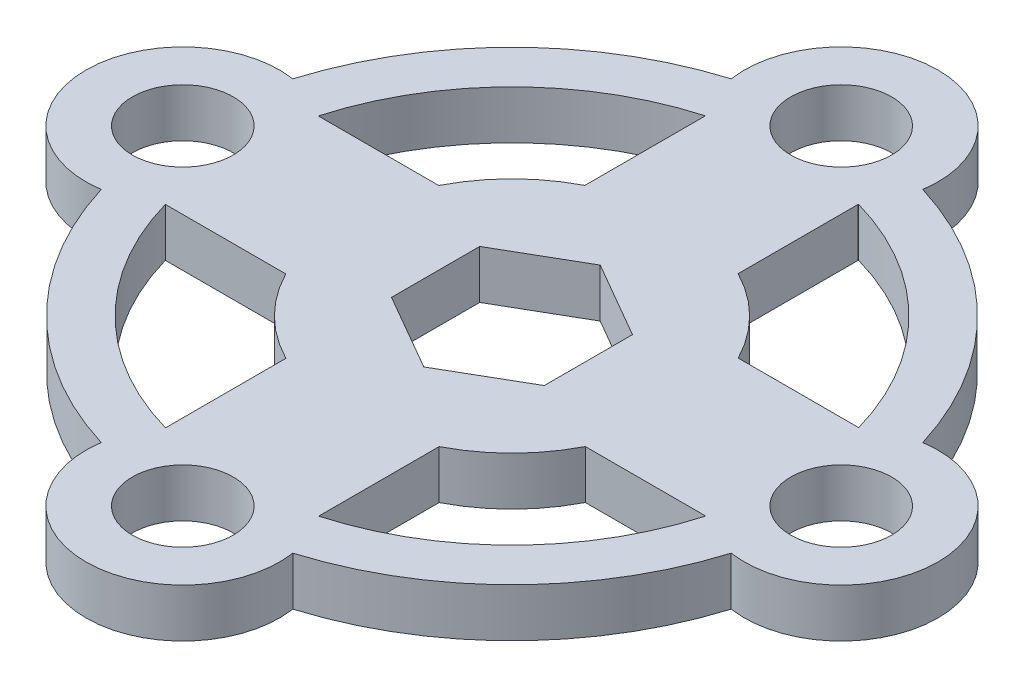
from build123d import *

# Parameters (mm, degrees)
SKETCH1_R           = 6.339
SKETCH1_R_2         = 3.302
SKETCH1_R_3         = 11
BOSS_EXTRUDE1_DEPTH = 3.175


with BuildPart() as part:
    # Sketch1 → Boss-Extrude1 (new body)
    with BuildSketch(Plane(origin=(0, 0, 0), x_dir=(1, 0, 0), z_dir=(0, 1, 0))):
        with BuildLine():
            ThreePointArc((-17.674506033, 5.017864634), (-12.991672891, 12.991672891), (-5.017864634, 17.674506033))
            ThreePointArc((-5.017864634, 17.674506033), (-5.832389069, 19.064824865), (-6.270051206, 20.615595113))
            ThreePointArc((-6.270051206, 20.615595113), (-15.236736921, 15.236736921), (-20.615595113, 6.270051206))
            ThreePointArc((-20.615595113, 6.270051206), (-19.064824865, 5.832389069), (-17.674506033, 5.017864634))
        make_face()
        with Locations((-21.548, 0)):
            Circle(SKETCH1_R)
        with Locations((-21.548, 0)):
            Circle(SKETCH1_R_2, mode=Mode.SUBTRACT)
        with BuildLine():
            ThreePointArc((-17.674506033, -5.017864634), (-19.064824865, -5.832389069), (-20.615595113, -6.270051206))
            ThreePointArc((-20.615595113, -6.270051206), (-15.236736921, -15.236736921), (-6.270051206, -20.615595113))
            ThreePointArc((-6.270051206, -20.615595113), (-5.832389069, -19.064824865), (-5.017864634, -17.674506033))
            ThreePointArc((-5.017864634, -17.674506033), (-12.991672891, -12.991672891), (-17.674506033, -5.017864634))
        make_face()
        with Locations((0, -21.548)):
            Circle(SKETCH1_R)
        with Locations((0, -21.548)):
            Circle(SKETCH1_R_2, mode=Mode.SUBTRACT)
        with BuildLine():
            ThreePointArc((-9.788821916, -5.017864634), (-10.999995425, -0.010032833), (-9.797958971, 5))
            Line((-9.797958971, 5), (-17.651473213, 5))
            ThreePointArc((-17.651473213, 5), (-15.852255786, 2.782340534), (-15.209, 0))
            ThreePointArc((-15.209, 0), (-15.85866791, -2.795428656), (-17.674506033, -5.017864634))
            Line((-17.674506033, -5.017864634), (-9.788821916, -5.017864634))
        make_face()
        with BuildLine():
            ThreePointArc((5.017864634, -9.788821916), (0.010032833, -10.999995425), (-5, -9.797958971))
            Line((-5, -9.797958971), (-5, -17.651473213))
            ThreePointArc((-5, -17.651473213), (0.014574429, -15.209016755), (5.017864634, -17.674506033))
            Line((5.017864634, -17.674506033), (5.017864634, -9.788821916))
        make_face()
        Circle(SKETCH1_R_3)
        Polygon((5, 2.886751346), (0, 5.773502692), (-5, 2.886751346), (-5, -2.886751346), (0, -5.773502692), (5, -2.886751346), align=None, mode=Mode.SUBTRACT)
        with BuildLine():
            ThreePointArc((5, 17.651473213), (-0.014574429, 15.209016755), (-5.017864634, 17.674506033))
            Line((-5.017864634, 17.674506033), (-5.017864634, 9.788821916))
            ThreePointArc((-5.017864634, 9.788821916), (-0.010032833, 10.999995425), (5, 9.797958971))
            Line((5, 9.797958971), (5, 17.651473213))
        make_face()
        with Locations((0, 21.548)):
            Circle(SKETCH1_R)
        with Locations((0, 21.548)):
            Circle(SKETCH1_R_2, mode=Mode.SUBTRACT)
        with BuildLine():
            ThreePointArc((6.270051206, 20.615595113), (5.832389069, 19.064824865), (5.017864634, 17.674506033))
            ThreePointArc((5.017864634, 17.674506033), (12.991672891, 12.991672891), (17.674506033, 5.017864634))
            ThreePointArc((17.674506033, 5.017864634), (19.064824865, 5.832389069), (20.615595113, 6.270051206))
            ThreePointArc((20.615595113, 6.270051206), (15.236736921, 15.236736921), (6.270051206, 20.615595113))
        make_face()
        with BuildLine():
            Line((17.674506033, 5.017864634), (9.788821916, 5.017864634))
            ThreePointArc((9.788821916, 5.017864634), (10.692919178, 2.580984204), (11, 0))
            ThreePointArc((11, 0), (10.695268783, -2.571230378), (9.797958971, -5))
            Line((9.797958971, -5), (17.651473213, -5))
            ThreePointArc((17.651473213, -5), (15.209016755, 0.014574429), (17.674506033, 5.017864634))
        make_face()
        with Locations((21.548, 0)):
            Circle(SKETCH1_R)
        with Locations((21.548, 0)):
            Circle(SKETCH1_R_2, mode=Mode.SUBTRACT)
        with BuildLine():
            ThreePointArc((20.615595113, -6.270051206), (19.064824865, -5.832389069), (17.674506033, -5.017864634))
            ThreePointArc((17.674506033, -5.017864634), (12.991672891, -12.991672891), (5.017864634, -17.674506033))
            ThreePointArc((5.017864634, -17.674506033), (5.832389069, -19.064824865), (6.270051206, -20.615595113))
            ThreePointArc((6.270051206, -20.615595113), (15.236736921, -15.236736921), (20.615595113, -6.270051206))
        make_face()
    extrude(amount=BOSS_EXTRUDE1_DEPTH)


solid = part.part
